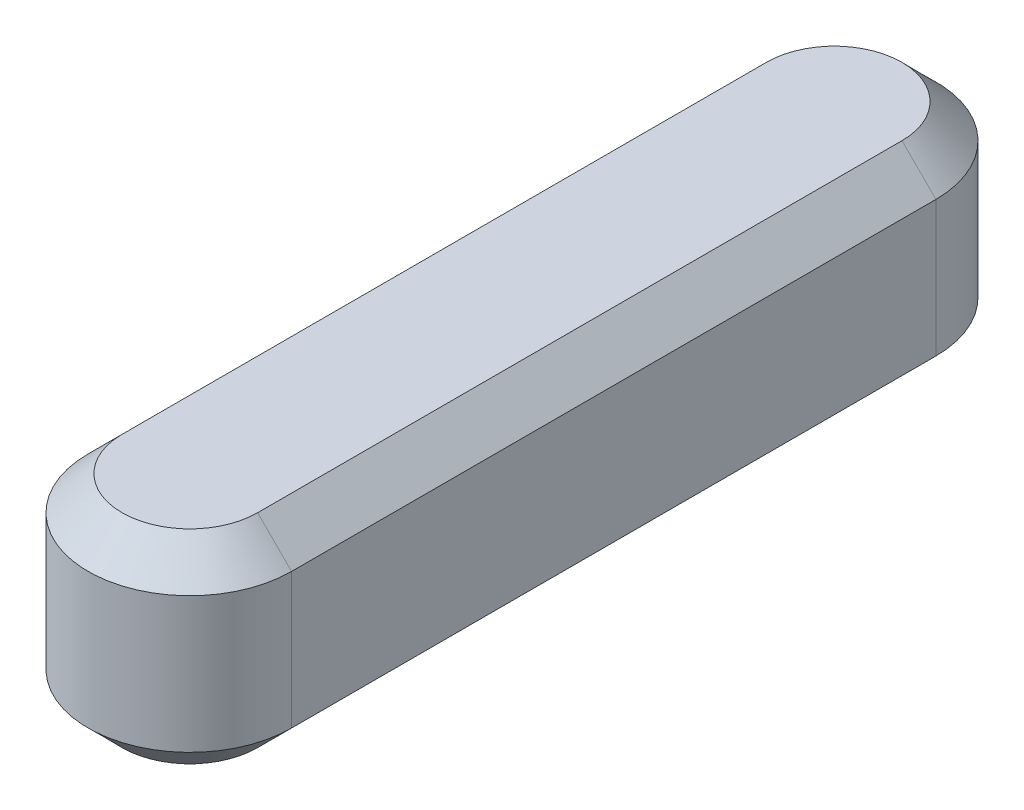
from build123d import *

# Parameters (mm, degrees)
BOSS_EXTRUDE1_DEPTH = 6
CHAMFER2_SIZE       = 1


with BuildPart() as part:
    # Sketch1 → Boss-Extrude1 (new body)
    with BuildSketch(Plane(origin=(0, 0, 0), x_dir=(1, 0, 0), z_dir=(0, 1, 0))):
        with BuildLine():
            Line((3, 0), (3, 19))
            ThreePointArc((3, 19), (0, 22), (-3, 19))
            Line((-3, 19), (-3, 0))
            ThreePointArc((-3, 0), (0, -3), (3, 0))
        make_face()
    extrude(amount=BOSS_EXTRUDE1_DEPTH)

    # Chamfer2
    chamfer2_edges = [part.edges().sort_by_distance(p)[0] for p in [
        (0, 6, -22),
        (-3, 6, -9.5),
        (0, 6, 3),
        (-3, 0, -9.5),
        (0, 0, -22),
        (3, 0, -9.5),
        (0, 0, 3),
        (3, 6, -9.5),
    ]]
    chamfer(chamfer2_edges, length=CHAMFER2_SIZE)


solid = part.part
